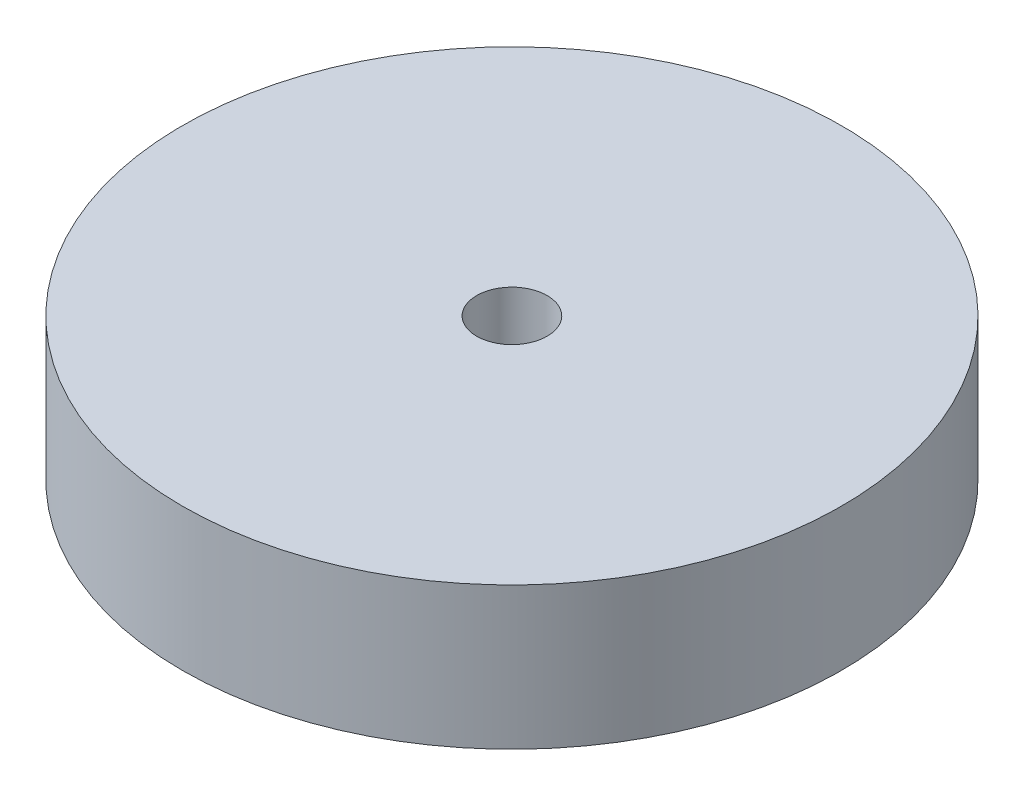
from build123d import *

# Parameters (mm, degrees)
SKETCH2_R           = 200
SKETCH2_R_2         = 21.39
BOSS_EXTRUDE1_DEPTH = 86.36


with BuildPart() as part:
    # Sketch2 → Boss-Extrude1 (new body)
    with BuildSketch(Plane(origin=(0, 0, 0), x_dir=(1, 0, 0), z_dir=(0, 1, 0))):
        Circle(SKETCH2_R)
        Circle(SKETCH2_R_2, mode=Mode.SUBTRACT)
    extrude(amount=BOSS_EXTRUDE1_DEPTH)


solid = part.part
